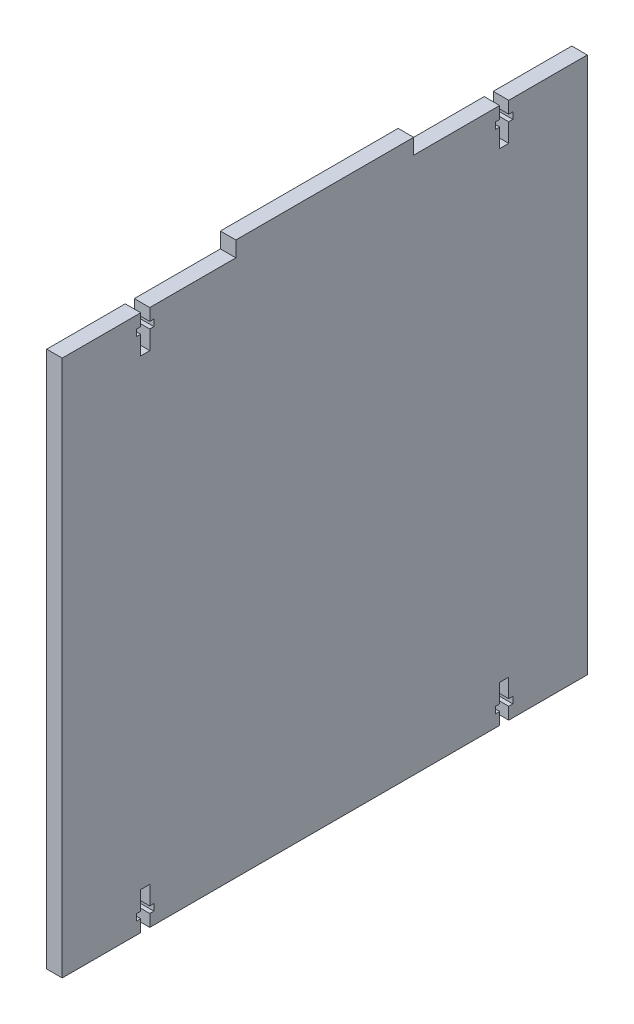
from build123d import *

# Parameters (mm, degrees)
SKETCH1_W            = 173.89
SKETCH1_H            = 177.8
MAIN_DEPTH           = 5.13
T_SLOT_DEPTH         = 5.13
LPATTERN2_COUNT      = 2
LPATTERN2_PITCH      = 118.88
MIRROR1_COPY_1_DEPTH = 5.13
SKETCH6_W            = 5.13
SKETCH6_H            = 58.88
TOOTH_DEPTH          = 5.13


with BuildPart() as part:
    # Sketch1 → Main (new body)
    with BuildSketch(Plane(origin=(0, 0, 0), x_dir=(0, 0, -1), z_dir=(1, 0, 0))):
        with Locations((51.252197546, -50.943101868)):
            Rectangle(SKETCH1_W, SKETCH1_H)
    extrude(amount=MAIN_DEPTH)

    # Sketch2 → t-slot (cut)
    with BuildSketch(Plane(origin=(5.13, 0, 0), x_dir=(0, 0, -1), z_dir=(1, 0, 0))):
        Polygon((-9.687802454, 37.956898132), (-6.690802454, 37.956898132), (-6.690802454, 33.961898132), (-5.331802454, 33.961898132), (-5.331802454, 31.794898132), (-6.690802454, 31.794898132), (-6.690802454, 25.587898132), (-9.687802454, 25.587898132), (-9.687802454, 31.794898132), (-11.046802454, 31.794898132), (-11.046802454, 33.961898132), (-9.687802454, 33.961898132), align=None)
    t_slot = extrude(amount=-T_SLOT_DEPTH, mode=Mode.SUBTRACT)

    # LPattern2: t-slot ×2
    with Locations(*[(0, 0, -i * LPATTERN2_PITCH) for i in range(1, LPATTERN2_COUNT)]):
        add(t_slot, mode=Mode.SUBTRACT)

    # Mirror1: t-slot across plane
    add(t_slot.mirror(Plane(origin=(0, -50.943101868, 0), x_dir=(0, 0, 1), z_dir=(0, -1, 0))), mode=Mode.SUBTRACT)

    # Mirror1 copy 1 sketch → Mirror1 copy 1 (cut)
    with BuildSketch(Plane(origin=(5.13, -101.886203737, -118.88), x_dir=(0, 0, -1), z_dir=(1, 0, 0))):
        Polygon((-9.687802454, -37.956898132), (-6.690802454, -37.956898132), (-6.690802454, -33.961898132), (-5.331802454, -33.961898132), (-5.331802454, -31.794898132), (-6.690802454, -31.794898132), (-6.690802454, -25.587898132), (-9.687802454, -25.587898132), (-9.687802454, -31.794898132), (-11.046802454, -31.794898132), (-11.046802454, -33.961898132), (-9.687802454, -33.961898132), align=None)
    extrude(amount=-MIRROR1_COPY_1_DEPTH, mode=Mode.SUBTRACT)

    # Sketch6 → Tooth (add)
    with BuildSketch(Plane(origin=(0, 37.956898132, 0), x_dir=(1, 0, 0), z_dir=(0, 1, 0))):
        with Locations((2.565, 51.252197546)):
            Rectangle(SKETCH6_W, SKETCH6_H)
    extrude(amount=TOOTH_DEPTH)


solid = part.part
